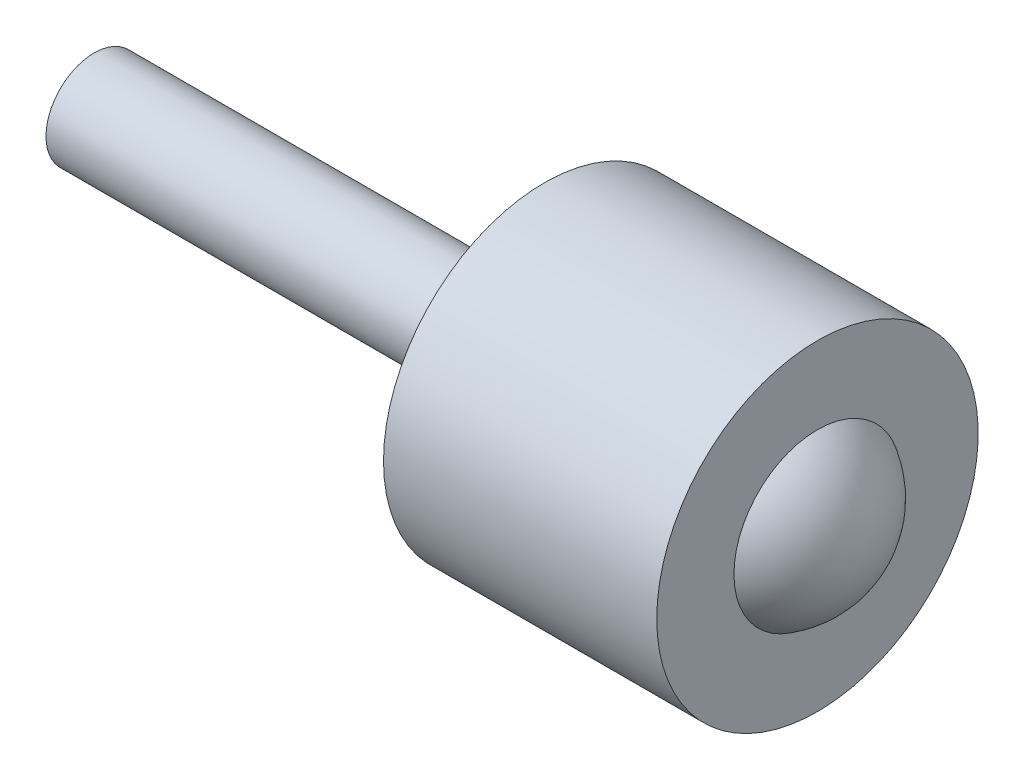
from build123d import *


with BuildPart() as part:
    # Sketch1 → Revolve1 (revolve)
    with BuildSketch(Plane.XY):
        with BuildLine():
            Line((0, 0), (48, 0))
            ThreePointArc((48, 0), (47.196152423, 3), (45, 5.196152423))
            Line((45, 5.196152423), (45, 10))
            Line((45, 10), (28, 10))
            Line((28, 10), (28, 3))
            Line((28, 3), (0, 3))
            Line((0, 3), (0, 0))
        make_face()
    revolve(axis=Axis((-2.4, 0, 0), (1, 0, 0)))


solid = part.part
